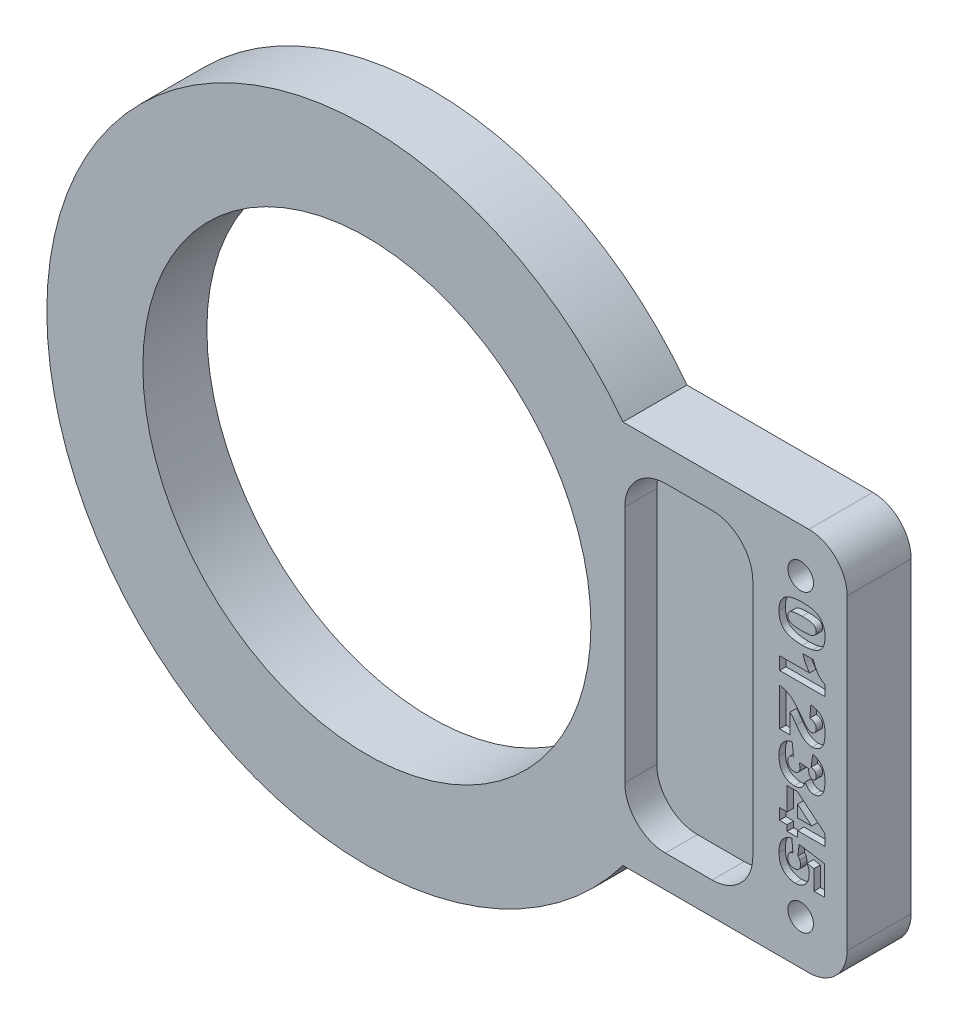
from build123d import *

# Parameters (mm, degrees)
SKETCH3_R           = 1
BOSS_EXTRUDE1_DEPTH = 5
CUT_EXTRUDE1_DEPTH  = 2.5
CUT_EXTRUDE2_DEPTH  = 0.5


with BuildPart() as part:
    # Sketch3 → Boss-Extrude1 (new body)
    with BuildSketch(Plane.XY):
        with BuildLine():
            Line((85.334209841, -51.513768595), (77.8189172, -51.513768595))
            Line((77.8189172, -51.513768595), (77.8189172, -48.776512323))
            ThreePointArc((77.8189172, -48.776512323), (47.833910572, -36.513779788), (77.8189172, -24.251047254))
            Line((77.8189172, -24.251047254), (77.8189172, -21.513790982))
            Line((77.8189172, -21.513790982), (85.334209841, -21.513790982))
            ThreePointArc((85.334209841, -21.513790982), (40.333677864, -36.513779788), (85.334209841, -51.513768595))
        make_face()
        with BuildLine():
            Line((77.8189172, -48.776512323), (77.8189172, -51.513768595))
            Line((77.8189172, -51.513768595), (85.334209841, -51.513768595))
            ThreePointArc((85.334209841, -51.513768595), (86.252702425, -50.203768189), (87.085522281, -48.837700556))
            ThreePointArc((87.085522281, -48.837700556), (85.646808429, -47.740125582), (85.101047033, -46.014810286))
            Line((85.101047033, -46.014810286), (85.101047033, -27.012749291))
            ThreePointArc((85.101047033, -27.012749291), (85.646808429, -25.287433995), (87.085522281, -24.189859021))
            ThreePointArc((87.085522281, -24.189859021), (86.252702425, -22.823791388), (85.334209841, -21.513790982))
            Line((85.334209841, -21.513790982), (77.8189172, -21.513790982))
            Line((77.8189172, -21.513790982), (77.8189172, -24.251047254))
            ThreePointArc((77.8189172, -24.251047254), (81.531713132, -29.889491758), (82.833910563, -36.513779788))
            ThreePointArc((82.833910563, -36.513779788), (81.531713132, -43.138067819), (77.8189172, -48.776512323))
        make_face()
        with BuildLine():
            ThreePointArc((87.085522281, -48.837700556), (86.252702425, -50.203768189), (85.334209841, -51.513768595))
            Line((85.334209841, -51.513768595), (99.849369341, -51.513768595))
            ThreePointArc((99.849369341, -51.513768595), (101.970689685, -50.635088938), (102.849369341, -48.513768595))
            Line((102.849369341, -48.513768595), (102.849369341, -24.513790982))
            ThreePointArc((102.849369341, -24.513790982), (101.970689685, -22.392470638), (99.849369341, -21.513790982))
            Line((99.849369341, -21.513790982), (85.334209841, -21.513790982))
            ThreePointArc((85.334209841, -21.513790982), (86.252702425, -22.823791388), (87.085522281, -24.189859021))
            ThreePointArc((87.085522281, -24.189859021), (87.585620419, -24.057358386), (88.101047033, -24.012749291))
            Line((88.101047033, -24.012749291), (92.567239508, -24.012749291))
            ThreePointArc((92.567239508, -24.012749291), (94.688559851, -24.891428948), (95.567239508, -27.012749291))
            Line((95.567239508, -27.012749291), (95.567239508, -46.014810286))
            ThreePointArc((95.567239508, -46.014810286), (94.688559851, -48.136130629), (92.567239508, -49.014810286))
            Line((92.567239508, -49.014810286), (88.101047033, -49.014810286))
            ThreePointArc((88.101047033, -49.014810286), (87.585620419, -48.970201191), (87.085522281, -48.837700556))
        make_face()
        with Locations((99.218411483, -48.042667346)):
            Circle(SKETCH3_R, mode=Mode.SUBTRACT)
        with Locations((99.218411483, -24.98489223)):
            Circle(SKETCH3_R, mode=Mode.SUBTRACT)
        with BuildLine():
            ThreePointArc((90.334143271, -36.513779788), (89.508349441, -42.886231464), (87.085522281, -48.837700556))
            ThreePointArc((87.085522281, -48.837700556), (87.585620419, -48.970201191), (88.101047033, -49.014810286))
            Line((88.101047033, -49.014810286), (92.567239508, -49.014810286))
            ThreePointArc((92.567239508, -49.014810286), (94.688559851, -48.136130629), (95.567239508, -46.014810286))
            Line((95.567239508, -46.014810286), (95.567239508, -27.012749291))
            ThreePointArc((95.567239508, -27.012749291), (94.688559851, -24.891428948), (92.567239508, -24.012749291))
            Line((92.567239508, -24.012749291), (88.101047033, -24.012749291))
            ThreePointArc((88.101047033, -24.012749291), (87.585620419, -24.057358386), (87.085522281, -24.189859021))
            ThreePointArc((87.085522281, -24.189859021), (89.508349441, -30.141328113), (90.334143271, -36.513779788))
        make_face()
        with BuildLine():
            ThreePointArc((85.101047033, -46.014810286), (85.646808429, -47.740125582), (87.085522281, -48.837700556))
            ThreePointArc((87.085522281, -48.837700556), (89.508349441, -42.886231464), (90.334143271, -36.513779788))
            ThreePointArc((90.334143271, -36.513779788), (89.508349441, -30.141328113), (87.085522281, -24.189859021))
            ThreePointArc((87.085522281, -24.189859021), (85.646808429, -25.287433995), (85.101047033, -27.012749291))
            Line((85.101047033, -27.012749291), (85.101047033, -46.014810286))
        make_face()
    extrude(amount=-BOSS_EXTRUDE1_DEPTH)

    # Model → Cut-Extrude1 (cut)
    with BuildSketch(Plane.XY):
        with BuildLine():
            Line((92.302516954, -49.013779785), (88.652516955, -49.013779785))
            add(Edge.make_bspline(
                [(88.652516955, -49.013779785), (86.906266956, -49.013779785), (85.477516956, -47.585029786), (85.477516956, -45.838779786)],
                knots=[1, 1, 1, 1, 2, 2, 2, 2], degree=3))
            Line((85.477516956, -45.838779786), (85.477516956, -27.188779791))
            add(Edge.make_bspline(
                [(85.477516956, -27.188779791), (85.477516956, -25.442529791), (86.906266956, -24.013779792), (88.652516955, -24.013779792)],
                knots=[3, 3, 3, 3, 4, 4, 4, 4], degree=3))
            Line((88.652516955, -24.013779792), (92.302516954, -24.013779792))
            add(Edge.make_bspline(
                [(92.302516954, -24.013779792), (94.048766954, -24.013779792), (95.477516954, -25.442529791), (95.477516954, -27.188779791)],
                knots=[5, 5, 5, 5, 6, 6, 6, 6], degree=3))
            Line((95.477516954, -27.188779791), (95.477516954, -45.838779786))
            add(Edge.make_bspline(
                [(95.477516954, -45.838779786), (95.477516954, -47.585029786), (94.048766954, -49.013779785), (92.302516954, -49.013779785)],
                knots=[7, 7, 7, 7, 8, 8, 8, 8], degree=3))
        make_face()
    extrude(amount=-CUT_EXTRUDE1_DEPTH, mode=Mode.SUBTRACT)

    # Sketch5 → Cut-Extrude2 (cut)
    with BuildSketch(Plane(origin=(134.172146557, 79.465455212, 0), x_dir=(0, -1, 0), z_dir=(0, 0, 1))):
        with BuildLine():
            add(Edge.make_bspline(
                [(106.1671856, -34.837550723), (106.167446046, -34.797063844), (106.167956427, -34.717724123), (106.172321705, -34.60096976), (106.179336701, -34.488707607), (106.189200453, -34.380934027), (106.201876598, -34.277876797), (106.21761047, -34.179590527), (106.235620669, -34.08584492), (106.257987349, -33.997175231), (106.282114922, -33.912758881), (106.308666885, -33.832949322), (106.338753917, -33.75786335), (106.371464248, -33.687451756), (106.406617796, -33.62111012), (106.445918976, -33.560267001), (106.487206913, -33.503630078), (106.54603984, -33.434429843), (106.627964619, -33.356422242), (106.738227535, -33.27546868), (106.861081891, -33.208053037), (106.994977415, -33.151749861), (107.140994298, -33.108466811), (107.298758996, -33.078552874), (107.468344894, -33.059805594), (107.585458207, -33.057493545), (107.645878782, -33.056300723)],
                knots=[0, 0, 0, 0, 1.087591881, 2.13128891, 3.138140209, 4.108914138, 5.038156313, 5.926884649, 6.782501702, 7.601552758, 8.382534381, 9.140733058, 9.859947563, 10.554209912, 11.225728598, 11.87495301, 12.498241101, 13.107351257, 14.312855526, 15.527634648, 16.771709977, 18.068615969, 19.42276522, 20.854627635, 22.377253613, 24, 24, 24, 24], degree=3))
            add(Edge.make_bspline(
                [(107.645878782, -33.056300723), (107.703199434, -33.057453344), (107.812625525, -33.059653715), (107.968906989, -33.074414325), (108.108904696, -33.102134579), (108.233742001, -33.139782804), (108.344953728, -33.186568333), (108.444830992, -33.239836769), (108.534363766, -33.29947078), (108.612669735, -33.366048799), (108.681193174, -33.436685373), (108.742772933, -33.508720105), (108.796955021, -33.582237264), (108.843133511, -33.658999822), (108.883060968, -33.739777591), (108.919581582, -33.8256265), (108.950576671, -33.918442286), (108.967942265, -33.9828165), (108.976844691, -34.015817769)],
                knots=[0, 0, 0, 0, 1.532758214, 2.92606128, 4.191114603, 5.342542327, 6.406514669, 7.411909621, 8.365259272, 9.277101494, 10.154475564, 10.994207034, 11.809606612, 12.593434151, 13.38610729, 14.217325278, 15.086116559, 16, 16, 16, 16], degree=3))
            add(Edge.make_bspline(
                [(108.976844691, -34.015817769), (108.992151319, -34.080984772), (109.02291357, -34.211953111), (109.053512122, -34.412769379), (109.072514063, -34.6177194), (109.075015262, -34.755832393), (109.076276509, -34.82547686)],
                knots=[0, 0, 0, 0, 0.98198754, 1.973533715, 2.978139842, 4, 4, 4, 4], degree=3))
            add(Edge.make_bspline(
                [(109.076276509, -34.82547686), (109.075465574, -34.901738452), (109.073899771, -35.048989037), (109.057914056, -35.261884762), (109.032947754, -35.458800067), (108.997725335, -35.640247536), (108.952183214, -35.806078002), (108.895289394, -35.95612763), (108.828812887, -36.090498305), (108.751444331, -36.209934586), (108.661065998, -36.314421643), (108.555776096, -36.404473861), (108.435299121, -36.479659909), (108.300569476, -36.541910266), (108.150808832, -36.589038611), (107.986830636, -36.622578869), (107.808105788, -36.64341401), (107.684054247, -36.645911951), (107.619600373, -36.647209814)],
                knots=[0, 0, 0, 0, 1.355222045, 2.616746286, 3.792100794, 4.881385083, 5.899230633, 6.844809326, 7.729242134, 8.559026746, 9.367323913, 10.17605905, 11.01191325, 11.883571865, 12.807079121, 13.795717036, 14.854713345, 16, 16, 16, 16], degree=3))
            add(Edge.make_bspline(
                [(107.619600373, -36.647209814), (107.583135067, -36.646795479), (107.511803408, -36.645984977), (107.407229486, -36.639810161), (107.308250586, -36.62815046), (107.214437524, -36.613743305), (107.126285456, -36.593628405), (107.043178879, -36.569731397), (106.965489633, -36.541401001), (106.86996876, -36.497808206), (106.75924415, -36.432309293), (106.639259715, -36.336656309), (106.529938227, -36.226023072), (106.469776316, -36.140802256), (106.439202646, -36.097493905)],
                knots=[0, 0, 0, 0, 0.962031703, 1.881879664, 2.761979937, 3.590622586, 4.384597812, 5.1455833, 5.870765821, 6.563934203, 7.913599601, 9.251901546, 10.603444349, 12, 12, 12, 12], degree=3))
            add(Edge.make_bspline(
                [(106.439202646, -36.097493905), (106.418266972, -36.063125053), (106.374034352, -35.990510987), (106.321487135, -35.866980731), (106.275464011, -35.726426551), (106.236234806, -35.5700297), (106.205805115, -35.400056331), (106.183057582, -35.22015343), (106.169365129, -35.031657198), (106.167922199, -34.903151402), (106.1671856, -34.837550723)],
                knots=[0, 0, 0, 0, 0.739508101, 1.562423156, 2.461722298, 3.458822943, 4.525732562, 5.636331831, 6.793375565, 8, 8, 8, 8], degree=3))
        make_face()
        with BuildLine():
            add(Edge.make_bspline(
                [(107.121731055, -34.848204133), (107.122172175, -34.899819096), (107.123018278, -34.998820617), (107.128500345, -35.140955646), (107.138118728, -35.270355185), (107.152329801, -35.386918426), (107.169574892, -35.491156376), (107.191375479, -35.5825284), (107.216303588, -35.661594814), (107.246674197, -35.728040761), (107.280287585, -35.784727385), (107.318377721, -35.832383318), (107.359034384, -35.873847819), (107.403892693, -35.907231254), (107.452425371, -35.933494357), (107.504487249, -35.951618973), (107.560097636, -35.963751069), (107.598463023, -35.964834719), (107.618179918, -35.965391633)],
                knots=[0, 0, 0, 0, 1.821909252, 3.494563902, 5.019956466, 6.400590685, 7.638410235, 8.747100251, 9.714301165, 10.559433052, 11.320433586, 12.034323191, 12.707949409, 13.364779561, 14.000375056, 14.647943435, 15.305145593, 16, 16, 16, 16], degree=3))
            add(Edge.make_bspline(
                [(107.618179918, -35.965391633), (107.643857468, -35.964151581), (107.694245523, -35.961718179), (107.767135463, -35.942841206), (107.834448745, -35.910842595), (107.896365377, -35.866188386), (107.951818447, -35.8076627), (107.998758131, -35.734162681), (108.038351897, -35.646919751), (108.063669686, -35.563595929), (108.07998423, -35.488144143), (108.091265879, -35.422497758), (108.10119426, -35.349560169), (108.108918349, -35.269004402), (108.11432555, -35.180872861), (108.118495827, -35.085213286), (108.121563847, -34.981983129), (108.121673984, -34.910706581), (108.121731055, -34.873772314)],
                knots=[0, 0, 0, 0, 0.916415337, 1.79831749, 2.668301498, 3.564798814, 4.509831996, 5.530070663, 6.665194469, 7.922271743, 8.632174375, 9.421805176, 10.300783619, 11.260830182, 12.3115562, 13.454245384, 14.680834273, 16, 16, 16, 16], degree=3))
            add(Edge.make_bspline(
                [(108.121731055, -34.873772314), (108.121288673, -34.82002696), (108.120440674, -34.717002653), (108.114993632, -34.569423639), (108.105353604, -34.435530106), (108.091197769, -34.315646487), (108.074040961, -34.209256584), (108.052050754, -34.116728094), (108.027324209, -34.037389509), (107.997215171, -33.970988772), (107.961827929, -33.916053954), (107.924713077, -33.867729265), (107.882155096, -33.827831432), (107.836494025, -33.794275106), (107.785754797, -33.769567804), (107.731746826, -33.750772296), (107.673287019, -33.740048091), (107.633137366, -33.738773909), (107.6124981, -33.738118905)],
                knots=[0, 0, 0, 0, 1.854070858, 3.554062822, 5.093710173, 6.483564629, 7.717457497, 8.808936618, 9.761959363, 10.58049486, 11.31461684, 12.012310019, 12.676654168, 13.320346403, 13.959515242, 14.615524135, 15.288298562, 16, 16, 16, 16], degree=3))
            add(Edge.make_bspline(
                [(107.6124981, -33.738118905), (107.591608271, -33.738698562), (107.550917765, -33.739827654), (107.49235468, -33.751533341), (107.438315664, -33.770097418), (107.38847635, -33.795825228), (107.343561212, -33.829810467), (107.302424505, -33.870553169), (107.267159255, -33.919674585), (107.235117612, -33.976095869), (107.208271074, -34.042802985), (107.184925542, -34.121024963), (107.165708237, -34.211586765), (107.149355192, -34.314703165), (107.137034929, -34.430155857), (107.127690387, -34.558295809), (107.123248108, -34.699025673), (107.122251101, -34.797065722), (107.121731055, -34.848204133)],
                knots=[0, 0, 0, 0, 0.737997139, 1.437516644, 2.102141925, 2.753771676, 3.411878008, 4.086813041, 4.793511383, 5.543335322, 6.376757621, 7.330304624, 8.427368638, 9.648338126, 11.021405169, 12.532439492, 14.191294945, 16, 16, 16, 16], degree=3))
        make_face(mode=Mode.SUBTRACT)
        with BuildLine():
            Line((111.6671856, -33.056300723), (111.6671856, -36.601755269))
            Line((111.6671856, -36.601755269), (110.6671856, -36.601755269))
            Line((110.6671856, -36.601755269), (110.6671856, -34.261556405))
            add(Edge.make_bspline(
                [(110.6671856, -34.261556405), (110.626941084, -34.291479657), (110.548491937, -34.349809433), (110.429228652, -34.429981495), (110.311586447, -34.50050606), (110.193934191, -34.565242018), (110.069362703, -34.622926013), (109.933150974, -34.678103499), (109.782797821, -34.73286522), (109.676795426, -34.766237678), (109.621731055, -34.783573451)],
                knots=[0, 0, 0, 0, 1.023561687, 1.995241831, 2.931714293, 3.82259212, 4.734876599, 5.731845621, 6.821776658, 8, 8, 8, 8], degree=3))
            Line((109.621731055, -34.783573451), (109.621731055, -33.965391633))
            add(Edge.make_bspline(
                [(109.621731055, -33.965391633), (109.663024803, -33.952436061), (109.743692185, -33.927127338), (109.859887011, -33.885091979), (109.969182565, -33.841735281), (110.071413424, -33.796470996), (110.166754012, -33.748951022), (110.254699174, -33.699401672), (110.335598967, -33.648013741), (110.433535384, -33.577468586), (110.545037094, -33.48114599), (110.662011485, -33.351549374), (110.766646975, -33.211227459), (110.821401147, -33.108225831), (110.849003782, -33.056300723)],
                knots=[0, 0, 0, 0, 0.988844751, 1.931709321, 2.822758702, 3.675235811, 4.48570532, 5.256019721, 5.980865129, 6.674516087, 8.012955474, 9.337912607, 10.657990402, 12, 12, 12, 12], degree=3))
            Line((110.849003782, -33.056300723), (111.6671856, -33.056300723))
        make_face()
        with BuildLine():
            Line((115.621731055, -36.601755269), (112.6671856, -36.601755269))
            add(Edge.make_bspline(
                [(112.6671856, -36.601755269), (112.671843428, -36.56544062), (112.681122977, -36.493092833), (112.704890217, -36.386163544), (112.732817934, -36.280480576), (112.76749685, -36.176380893), (112.810278641, -36.074716715), (112.857102356, -35.973538838), (112.912661705, -35.875110811), (112.973098446, -35.775861615), (113.045758441, -35.676785099), (113.130376717, -35.574106887), (113.23032556, -35.468885372), (113.34345291, -35.359533183), (113.470170359, -35.246467679), (113.611309454, -35.130226356), (113.765922521, -35.00930129), (113.875496508, -34.929770962), (113.932100373, -34.888687087)],
                knots=[0, 0, 0, 0, 0.798125275, 1.590063504, 2.386650706, 3.181830982, 3.980573995, 4.791293479, 5.611770483, 6.444247553, 7.324209591, 8.288770749, 9.344442884, 10.487375082, 11.719741268, 13.047247144, 14.47466329, 16, 16, 16, 16], degree=3))
            add(Edge.make_bspline(
                [(113.932100373, -34.888687087), (113.966534471, -34.863975112), (114.032551379, -34.816597419), (114.125778798, -34.746166377), (114.209432908, -34.67984071), (114.284709107, -34.619581462), (114.349828293, -34.562895756), (114.405746348, -34.511299851), (114.453204552, -34.464839827), (114.50121801, -34.409156955), (114.548439437, -34.343889685), (114.589849393, -34.266197503), (114.617107534, -34.190202885), (114.620228764, -34.13912422), (114.621731055, -34.11453936)],
                knots=[0, 0, 0, 0, 1.426735716, 2.735331656, 3.932690034, 5.020515582, 5.980894753, 6.838122453, 7.581977732, 8.214735694, 9.311631457, 10.284853698, 11.17447662, 12, 12, 12, 12], degree=3))
            add(Edge.make_bspline(
                [(114.621731055, -34.11453936), (114.620273039, -34.089256891), (114.617417578, -34.039742254), (114.593305581, -33.96857477), (114.554211134, -33.903786394), (114.500449483, -33.846472581), (114.435801622, -33.798607723), (114.361770139, -33.762845416), (114.279337608, -33.742051596), (114.221755124, -33.739457443), (114.192043555, -33.738118905)],
                knots=[0, 0, 0, 0, 0.952945949, 1.866303995, 2.804834556, 3.791947944, 4.814941972, 5.826815529, 6.878674284, 8, 8, 8, 8], degree=3))
            add(Edge.make_bspline(
                [(114.192043555, -33.738118905), (114.161145031, -33.73941994), (114.101680728, -33.741923785), (114.016738968, -33.762904121), (113.94097706, -33.798076609), (113.885428303, -33.83891909), (113.846268933, -33.878879473), (113.819150651, -33.914577506), (113.795603259, -33.956044113), (113.772871894, -34.001962995), (113.754356072, -34.053581603), (113.737956239, -34.110312663), (113.723742768, -34.172208107), (113.716435936, -34.215585169), (113.712640146, -34.238118905)],
                knots=[0, 0, 0, 0, 1.439477229, 2.770278312, 4.04952311, 5.312562752, 5.960562671, 6.653906719, 7.396155607, 8.18125893, 9.040559249, 9.948954118, 10.934512264, 12, 12, 12, 12], degree=3))
            Line((113.712640146, -34.238118905), (112.758094691, -34.163545042))
            add(Edge.make_bspline(
                [(112.758094691, -34.163545042), (112.762964669, -34.130578222), (112.772497093, -34.066049451), (112.792087253, -33.972862901), (112.812996096, -33.884729703), (112.837912473, -33.802524849), (112.865558608, -33.725683162), (112.895820909, -33.654230815), (112.930179067, -33.589071455), (112.978313937, -33.508802466), (113.049569739, -33.418469275), (113.150561775, -33.323213208), (113.267394607, -33.242275985), (113.376132971, -33.186038755), (113.471861961, -33.148499249), (113.551668587, -33.123859551), (113.637968559, -33.102627137), (113.730993748, -33.085825322), (113.83048946, -33.072172236), (113.936947133, -33.063421234), (114.049933118, -33.057574968), (114.127404943, -33.056733041), (114.1671856, -33.056300723)],
                knots=[0, 0, 0, 0, 0.989592556, 1.937013979, 2.827284947, 3.679299113, 4.486736888, 5.252174584, 5.981861435, 6.672880631, 8.030317246, 9.383357337, 10.782057359, 12.238191716, 13.008619595, 13.833745451, 14.717186414, 15.646773357, 16.640255679, 17.698985578, 18.818462498, 20, 20, 20, 20], degree=3))
            add(Edge.make_bspline(
                [(114.1671856, -33.056300723), (114.208618107, -33.056831481), (114.289381455, -33.057866074), (114.406922741, -33.062350813), (114.517536016, -33.071808614), (114.620880456, -33.084290604), (114.717136802, -33.100542734), (114.806271754, -33.120456826), (114.888506818, -33.143422791), (114.964038113, -33.170933303), (115.034217839, -33.201408149), (115.099892854, -33.236486833), (115.161612468, -33.275426777), (115.219361482, -33.318362461), (115.273769747, -33.364571733), (115.324005443, -33.415222702), (115.37131919, -33.469130293), (115.413593818, -33.527436306), (115.451703914, -33.588217476), (115.485665477, -33.650797546), (115.512802964, -33.7158415), (115.537115329, -33.782112797), (115.554163553, -33.850788944), (115.567504774, -33.920916423), (115.574283314, -33.992958163), (115.575606569, -34.041611543), (115.576276509, -34.066243905)],
                knots=[0, 0, 0, 0, 1.520214409, 2.96331587, 4.314320473, 5.592028486, 6.781488773, 7.894101563, 8.941615604, 9.911497389, 10.841025698, 11.746378512, 12.640369159, 13.515899531, 14.384509289, 15.256629472, 16.130909547, 17.01343449, 17.895446386, 18.761969182, 19.621893716, 20.479006308, 21.349047949, 22.214481793, 23.096023134, 24, 24, 24, 24], degree=3))
            add(Edge.make_bspline(
                [(115.576276509, -34.066243905), (115.575812654, -34.092554553), (115.574886222, -34.145103237), (115.564857239, -34.223093025), (115.551100862, -34.300392914), (115.530285046, -34.376625469), (115.503067909, -34.451967867), (115.47029054, -34.526690452), (115.431971155, -34.600547616), (115.387266219, -34.673945369), (115.335311713, -34.747876684), (115.27233525, -34.821539106), (115.201911259, -34.898265054), (115.120728416, -34.975926541), (115.030266548, -35.055161865), (114.929197758, -35.135085127), (114.820470747, -35.218766346), (114.74272809, -35.272328525), (114.702696964, -35.299908678)],
                knots=[0, 0, 0, 0, 0.799860441, 1.597513472, 2.388474526, 3.186809909, 3.997713199, 4.82322568, 5.667097207, 6.52667738, 7.43580813, 8.412238442, 9.472172286, 10.602795499, 11.827605265, 13.128826161, 14.521579684, 16, 16, 16, 16], degree=3))
            add(Edge.make_bspline(
                [(114.702696964, -35.299908678), (114.678988979, -35.315720459), (114.633593153, -35.345996707), (114.569170845, -35.39010293), (114.510631912, -35.430019018), (114.457868668, -35.466183072), (114.411487679, -35.499134508), (114.371603683, -35.528749986), (114.337008571, -35.553405735), (114.298835127, -35.583200879), (114.253327328, -35.62080611), (114.197024973, -35.669406388), (114.136012348, -35.723681486), (114.094851773, -35.763076114), (114.0734356, -35.783573451)],
                knots=[0, 0, 0, 0, 1.290297726, 2.470649887, 3.535060469, 4.498436346, 5.366972879, 6.11094909, 6.74773956, 7.290209297, 8.303122279, 9.420462908, 10.657846448, 12, 12, 12, 12], degree=3))
            Line((114.0734356, -35.783573451), (115.621731055, -35.783573451))
            Line((115.621731055, -35.783573451), (115.621731055, -36.601755269))
        make_face()
        with BuildLine():
            Line((116.985367418, -34.147209814), (116.030821964, -34.003033678))
            add(Edge.make_bspline(
                [(116.030821964, -34.003033678), (116.040848448, -33.965669684), (116.060510384, -33.892398893), (116.100102642, -33.787853681), (116.145670056, -33.689654562), (116.198112306, -33.598120759), (116.257172446, -33.513165079), (116.322984459, -33.43536111), (116.395056933, -33.363849336), (116.474234979, -33.298826214), (116.561353815, -33.240856014), (116.656992894, -33.19133377), (116.760822948, -33.149044115), (116.87346577, -33.1154956), (116.994457065, -33.088369466), (117.123853232, -33.069629169), (117.26166709, -33.057998105), (117.356318225, -33.056878097), (117.405111737, -33.056300723)],
                knots=[0, 0, 0, 0, 1.016473964, 1.99330546, 2.934409827, 3.859992667, 4.762972884, 5.650703162, 6.535286226, 7.428605855, 8.340018839, 9.280937971, 10.255228319, 11.282957832, 12.367105901, 13.512225285, 14.717529764, 16, 16, 16, 16], degree=3))
            add(Edge.make_bspline(
                [(117.405111737, -33.056300723), (117.46077223, -33.056794743), (117.568211754, -33.057748333), (117.723254576, -33.070283321), (117.866280796, -33.089107279), (117.997815032, -33.114781582), (118.117063319, -33.149477221), (118.224753346, -33.191328337), (118.32068435, -33.240743761), (118.404268846, -33.298872923), (118.476692933, -33.362415137), (118.540184406, -33.429270798), (118.592589966, -33.501144144), (118.637929404, -33.575758635), (118.67059495, -33.655872125), (118.695411472, -33.739018566), (118.709701172, -33.826406646), (118.711648725, -33.886032722), (118.712640146, -33.916385951)],
                knots=[0, 0, 0, 0, 1.517383578, 2.928952978, 4.238160805, 5.44974818, 6.579458997, 7.619995139, 8.595949147, 9.514581533, 10.388460386, 11.219690946, 12.022770555, 12.809943427, 13.594039736, 14.374380097, 15.172462533, 16, 16, 16, 16], degree=3))
            add(Edge.make_bspline(
                [(118.712640146, -33.916385951), (118.711448905, -33.951795826), (118.709096531, -34.021720648), (118.685131175, -34.123374141), (118.647991188, -34.220296558), (118.59476423, -34.311653286), (118.526202496, -34.397556826), (118.443030947, -34.477970386), (118.344983928, -34.55331893), (118.27141807, -34.595959606), (118.233236737, -34.618090496)],
                knots=[0, 0, 0, 0, 0.947905039, 1.871853284, 2.784216614, 3.722702492, 4.694201726, 5.722124319, 6.817762277, 8, 8, 8, 8], degree=3))
            add(Edge.make_bspline(
                [(118.233236737, -34.618090496), (118.264401268, -34.6263722), (118.323517193, -34.642081745), (118.404824304, -34.671596995), (118.475740048, -34.701098617), (118.51662121, -34.725816533), (118.535793555, -34.737408678)],
                knots=[0, 0, 0, 0, 1.184343163, 2.246577671, 3.177684428, 4, 4, 4, 4], degree=3))
            add(Edge.make_bspline(
                [(118.535793555, -34.737408678), (118.56311567, -34.756337227), (118.617450993, -34.793980315), (118.688574295, -34.863053177), (118.750139789, -34.940533093), (118.802434278, -35.026191757), (118.843815784, -35.120750459), (118.873683005, -35.224062857), (118.89156579, -35.335980462), (118.893476217, -35.413477944), (118.894458327, -35.453317769)],
                knots=[0, 0, 0, 0, 0.951607881, 1.892456733, 2.829478787, 3.782803609, 4.761379966, 5.779454616, 6.858464331, 8, 8, 8, 8], degree=3))
            add(Edge.make_bspline(
                [(118.894458327, -35.453317769), (118.892612718, -35.50484361), (118.888922808, -35.607858775), (118.856850465, -35.76019512), (118.805906375, -35.909161061), (118.747810266, -36.029159442), (118.691671368, -36.121138743), (118.644732727, -36.186727017), (118.593157478, -36.247921743), (118.538109834, -36.305904626), (118.477071052, -36.358307264), (118.412311324, -36.407379358), (118.34349997, -36.453291979), (118.269097229, -36.493542342), (118.190075373, -36.530208262), (118.105080517, -36.561034041), (118.014720814, -36.588598923), (117.917874231, -36.609116798), (117.81556263, -36.626513435), (117.707157308, -36.638045095), (117.592981314, -36.646469363), (117.514740399, -36.646959216), (117.474714009, -36.647209814)],
                knots=[0, 0, 0, 0, 1.476279031, 2.951511793, 4.443628516, 5.983059138, 6.763175725, 7.531864904, 8.29332487, 9.056749507, 9.821862739, 10.597178928, 11.386137227, 12.191286903, 13.020603339, 13.881952483, 14.781925957, 15.727428807, 16.718531961, 17.756896181, 18.852475743, 20, 20, 20, 20], degree=3))
            add(Edge.make_bspline(
                [(117.474714009, -36.647209814), (117.435648308, -36.646688366), (117.35985319, -36.645676654), (117.249176836, -36.641084152), (117.144946443, -36.631732366), (117.046812251, -36.619151097), (116.955084209, -36.602826389), (116.86952735, -36.583362508), (116.790744153, -36.558925748), (116.694416211, -36.523474232), (116.58388311, -36.468649894), (116.462900358, -36.389265436), (116.353565974, -36.296983035), (116.257064418, -36.189904296), (116.172211735, -36.068719314), (116.098370554, -35.933534513), (116.034782368, -35.784300338), (116.002159818, -35.678323633), (115.985367418, -35.623772314)],
                knots=[0, 0, 0, 0, 0.94717577, 1.837706665, 2.684707542, 3.483469276, 4.235542299, 4.942784163, 5.609086716, 6.233823944, 7.429971554, 8.590460291, 9.734697625, 10.888696137, 12.075012856, 13.313165115, 14.61695657, 16, 16, 16, 16], degree=3))
            Line((115.985367418, -35.623772314), (116.939912873, -35.510846178))
            add(Edge.make_bspline(
                [(116.939912873, -35.510846178), (116.945115352, -35.531511207), (116.955180955, -35.571493298), (116.97374116, -35.628398138), (116.994137471, -35.680478534), (117.017068462, -35.727260487), (117.040808234, -35.76994241), (117.068380471, -35.806581068), (117.096211926, -35.840098573), (117.138720686, -35.875798145), (117.196913451, -35.912493655), (117.275466045, -35.943252849), (117.362335626, -35.961929513), (117.42324334, -35.964209383), (117.454827646, -35.965391633)],
                knots=[0, 0, 0, 0, 1.013482904, 1.960856885, 2.845504117, 3.671577595, 4.438490576, 5.163839406, 5.850378691, 6.505144346, 7.795649977, 9.104842238, 10.498686967, 12, 12, 12, 12], degree=3))
            add(Edge.make_bspline(
                [(117.454827646, -35.965391633), (117.488126687, -35.963779545), (117.553101546, -35.960633955), (117.645995362, -35.935381371), (117.729713833, -35.89291712), (117.803723752, -35.835673079), (117.864549298, -35.763645208), (117.908517715, -35.679285004), (117.935819631, -35.584009041), (117.938512492, -35.516719653), (117.939912873, -35.48172686)],
                knots=[0, 0, 0, 0, 1.039415399, 2.028162539, 2.98091851, 3.956040558, 4.932536472, 5.902030713, 6.90898391, 8, 8, 8, 8], degree=3))
            add(Edge.make_bspline(
                [(117.939912873, -35.48172686), (117.938337254, -35.446303121), (117.935335081, -35.378806987), (117.911015054, -35.283353636), (117.869548149, -35.200452736), (117.810457899, -35.131755054), (117.737783315, -35.077460314), (117.652906432, -35.037546611), (117.555877306, -35.015064653), (117.487614588, -35.012292846), (117.451986737, -35.010846178)],
                knots=[0, 0, 0, 0, 1.105816862, 2.107015386, 3.053219165, 3.976769062, 4.911831574, 5.868217612, 6.887374708, 8, 8, 8, 8], degree=3))
            add(Edge.make_bspline(
                [(117.451986737, -35.010846178), (117.430189401, -35.011772104), (117.382422261, -35.013801197), (117.305173865, -35.023136685), (117.217051942, -35.041104917), (117.154834675, -35.055659183), (117.121731055, -35.063402996)],
                knots=[0, 0, 0, 0, 0.781109365, 1.711739477, 2.782497035, 4, 4, 4, 4], degree=3))
            Line((117.121731055, -35.063402996), (117.172157191, -34.319795042))
            add(Edge.make_bspline(
                [(117.172157191, -34.319795042), (117.196751135, -34.322567933), (117.239719429, -34.327412475), (117.282937425, -34.328544089), (117.301418555, -34.329027996)],
                knots=[0, 0, 0, 0, 1.144748428, 2, 2, 2, 2], degree=3))
            add(Edge.make_bspline(
                [(117.301418555, -34.329027996), (117.332760454, -34.328087837), (117.393153446, -34.326276236), (117.47973836, -34.308139868), (117.558185425, -34.278134168), (117.627324529, -34.237318819), (117.684958377, -34.188768659), (117.72670353, -34.133419981), (117.75402978, -34.073574368), (117.756742122, -34.031244615), (117.758094691, -34.010135951)],
                knots=[0, 0, 0, 0, 1.222475891, 2.355599977, 3.435433984, 4.488139095, 5.477788772, 6.355989587, 7.180177952, 8, 8, 8, 8], degree=3))
            add(Edge.make_bspline(
                [(117.758094691, -34.010135951), (117.757153849, -33.990338303), (117.755331693, -33.951995607), (117.736771888, -33.897742791), (117.706037115, -33.850442593), (117.663875713, -33.810506032), (117.612257104, -33.777484587), (117.550692017, -33.754042663), (117.480229229, -33.741019599), (117.430498005, -33.739117194), (117.404401509, -33.738118905)],
                knots=[0, 0, 0, 0, 0.944636713, 1.829506197, 2.706215999, 3.619562109, 4.587483607, 5.620444109, 6.75132628, 8, 8, 8, 8], degree=3))
            add(Edge.make_bspline(
                [(117.404401509, -33.738118905), (117.377560388, -33.73914103), (117.325660796, -33.741117396), (117.251663674, -33.758206713), (117.185595021, -33.78730203), (117.126167659, -33.827229248), (117.076483195, -33.884026754), (117.036057428, -33.956539529), (117.005357539, -34.046157364), (116.992338173, -34.111971814), (116.985367418, -34.147209814)],
                knots=[0, 0, 0, 0, 0.988061552, 1.910501065, 2.777503571, 3.636395657, 4.525876446, 5.529824988, 6.677432876, 8, 8, 8, 8], degree=3))
        make_face()
        Polygon((120.939912873, -36.010846178), (119.1671856, -36.010846178), (119.1671856, -35.197635951), (120.939912873, -33.056300723), (121.803549237, -33.056300723), (121.803549237, -35.19266436), (122.258094691, -35.19266436), (122.258094691, -36.010846178), (121.803549237, -36.010846178), (121.803549237, -36.601755269), (120.939912873, -36.601755269), align=None)
        Polygon((120.939912873, -35.19266436), (120.939912873, -34.092522314), (120.005253782, -35.19266436), align=None, mode=Mode.SUBTRACT)
        with BuildLine():
            Line((122.985367418, -33.101755269), (125.258094691, -33.101755269))
            Line((125.258094691, -33.101755269), (125.258094691, -33.919937087))
            Line((125.258094691, -33.919937087), (123.733236737, -33.919937087))
            Line((123.733236737, -33.919937087), (123.640196964, -34.456868905))
            add(Edge.make_bspline(
                [(123.640196964, -34.456868905), (123.693134979, -34.430218209), (123.795750399, -34.378558311), (123.955504174, -34.324635908), (124.113108747, -34.289784053), (124.218385696, -34.285621096), (124.270168555, -34.283573451)],
                knots=[0, 0, 0, 0, 1.076698682, 2.087080297, 3.059086994, 4, 4, 4, 4], degree=3))
            add(Edge.make_bspline(
                [(124.270168555, -34.283573451), (124.312578252, -34.284574114), (124.39551212, -34.286530951), (124.517129136, -34.300509168), (124.632123326, -34.325932061), (124.741822406, -34.358544857), (124.844434581, -34.403427748), (124.941682621, -34.456466691), (125.032392313, -34.520389249), (125.116329805, -34.593021967), (125.192005198, -34.673121515), (125.258966273, -34.758501777), (125.313953804, -34.850152571), (125.361083201, -34.945711005), (125.396449251, -35.046901642), (125.420995751, -35.153158387), (125.437429019, -35.264123684), (125.439075328, -35.340094441), (125.439912873, -35.378743905)],
                knots=[0, 0, 0, 0, 1.132770727, 2.215178666, 3.263220416, 4.275335202, 5.266733338, 6.248831308, 7.229482813, 8.224705259, 9.208775947, 10.168802407, 11.116651866, 12.058428085, 13.010402857, 13.972093935, 14.968320338, 16, 16, 16, 16], degree=3))
            add(Edge.make_bspline(
                [(125.439912873, -35.378743905), (125.437829703, -35.433816691), (125.433674649, -35.543663924), (125.401016578, -35.706498593), (125.348302204, -35.865948069), (125.286477938, -35.993818411), (125.228916859, -36.092802433), (125.179456476, -36.16248483), (125.126295197, -36.227714819), (125.069128857, -36.289039719), (125.006479735, -36.344561638), (124.940258101, -36.396772116), (124.869772707, -36.444668482), (124.794188659, -36.487303862), (124.713675136, -36.524964856), (124.628008252, -36.557769561), (124.537051138, -36.585256022), (124.440757629, -36.608043668), (124.338995228, -36.625614767), (124.231862097, -36.63848672), (124.119214506, -36.645275278), (124.042430351, -36.646554802), (124.0031231, -36.647209814)],
                knots=[0, 0, 0, 0, 1.528130795, 3.047983433, 4.592369601, 6.180001838, 6.981509312, 7.769315725, 8.549517224, 9.316763787, 10.094080368, 10.871202386, 11.656949529, 12.457567084, 13.277961217, 14.122693581, 15.002230064, 15.914179549, 16.868381245, 17.867938249, 18.908557575, 20, 20, 20, 20], degree=3))
            add(Edge.make_bspline(
                [(124.0031231, -36.647209814), (123.947458409, -36.646485597), (123.840232978, -36.645090555), (123.685640051, -36.631863816), (123.543052803, -36.612150267), (123.412350855, -36.582379778), (123.292595783, -36.543467117), (123.182073686, -36.497897189), (123.080999137, -36.442697883), (122.989462634, -36.379435536), (122.906833036, -36.309561082), (122.833105682, -36.234611234), (122.766156721, -36.156449867), (122.708074653, -36.071966547), (122.655986852, -35.980022862), (122.609920366, -35.878471865), (122.566599972, -35.766954345), (122.543044863, -35.688118332), (122.530821964, -35.647209814)],
                knots=[0, 0, 0, 0, 1.372442733, 2.643700385, 3.823567361, 4.919749957, 5.944446967, 6.925729544, 7.863677766, 8.778668563, 9.665241588, 10.528063412, 11.369039113, 12.199840812, 13.052169595, 13.971675405, 14.947489244, 16, 16, 16, 16], degree=3))
            Line((122.530821964, -35.647209814), (123.485367418, -35.556300723))
            add(Edge.make_bspline(
                [(123.485367418, -35.556300723), (123.492397927, -35.588200332), (123.505923154, -35.649568497), (123.545974124, -35.732375277), (123.595681679, -35.804918061), (123.659921312, -35.86292645), (123.732952445, -35.908750415), (123.813494466, -35.941431784), (123.900519634, -35.962179347), (123.960863003, -35.964303859), (123.991759464, -35.965391633)],
                knots=[0, 0, 0, 0, 1.097106747, 2.110603618, 3.077835564, 4.043223531, 5.003820462, 5.969702698, 6.960465698, 8, 8, 8, 8], degree=3))
            add(Edge.make_bspline(
                [(123.991759464, -35.965391633), (124.026019856, -35.964097682), (124.092386795, -35.961591128), (124.186842251, -35.936304549), (124.272659705, -35.897176634), (124.335119062, -35.850485887), (124.379046077, -35.80619841), (124.407377023, -35.768260776), (124.431806827, -35.726643567), (124.451773847, -35.681156452), (124.466337787, -35.631394048), (124.477984244, -35.578307512), (124.484189444, -35.520936124), (124.484966137, -35.481503361), (124.485367418, -35.461130269)],
                knots=[0, 0, 0, 0, 1.539965673, 2.983118394, 4.371334758, 5.766088172, 6.467346732, 7.175382453, 7.892275449, 8.6371704, 9.406248233, 10.223979698, 11.082412157, 12, 12, 12, 12], degree=3))
            add(Edge.make_bspline(
                [(124.485367418, -35.461130269), (124.484985841, -35.440516864), (124.484247027, -35.400605035), (124.477773637, -35.342625629), (124.467155199, -35.288986709), (124.4533112, -35.239202196), (124.433950121, -35.194204692), (124.410331766, -35.153636148), (124.383329128, -35.116546686), (124.340208084, -35.074349629), (124.278283487, -35.029893293), (124.192417099, -34.991488725), (124.095092105, -34.969816024), (124.02666876, -34.966906342), (123.991049237, -34.965391633)],
                knots=[0, 0, 0, 0, 0.928881123, 1.798506635, 2.625105205, 3.391671582, 4.123045287, 4.825838584, 5.504482718, 6.183546156, 7.536843935, 8.917132029, 10.395134148, 12, 12, 12, 12], degree=3))
            add(Edge.make_bspline(
                [(123.991049237, -34.965391633), (123.967329709, -34.966043903), (123.920357814, -34.967335597), (123.850684407, -34.978654005), (123.782215275, -34.995967598), (123.738280226, -35.013430236), (123.716191282, -35.022209814)],
                knots=[0, 0, 0, 0, 1.006826498, 1.99382335, 2.991367353, 4, 4, 4, 4], degree=3))
            add(Edge.make_bspline(
                [(123.716191282, -35.022209814), (123.698948155, -35.03012478), (123.662937848, -35.046654282), (123.609801959, -35.080649531), (123.554158227, -35.12207713), (123.517792313, -35.154486551), (123.498861737, -35.171357542)],
                knots=[0, 0, 0, 0, 0.85886973, 1.793651557, 2.851467161, 4, 4, 4, 4], degree=3))
            Line((123.498861737, -35.171357542), (122.6671856, -35.073346178))
            Line((122.6671856, -35.073346178), (122.985367418, -33.101755269))
        make_face()
    extrude(amount=-CUT_EXTRUDE2_DEPTH, mode=Mode.SUBTRACT)


solid = part.part
